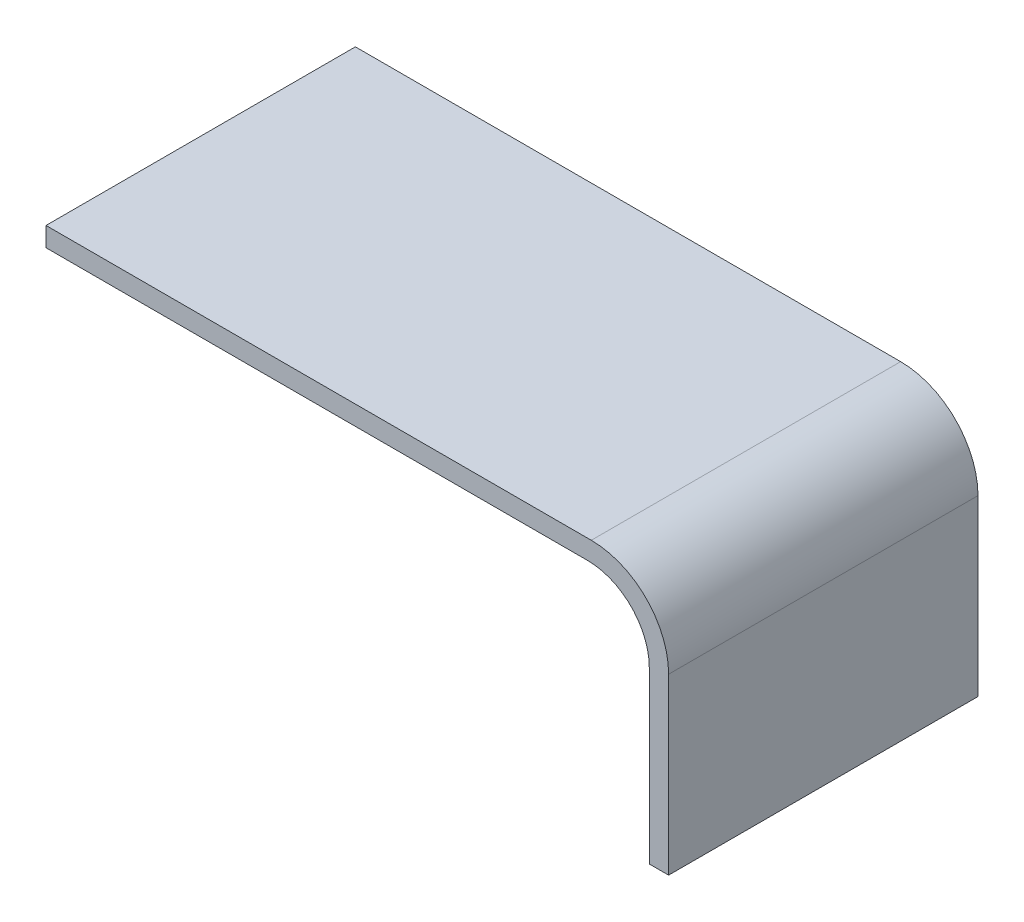
from build123d import *

# Parameters (mm, degrees)
BOSS_EXTRUDE1_DEPTH = 101.6


with BuildPart() as part:
    # Sketch2 → Boss-Extrude1 (new body)
    with BuildSketch(Plane.XY):
        with BuildLine():
            Line((204.47, 0), (383.54, 0))
            ThreePointArc((383.54, 0), (401.500512242, -7.439487758), (408.94, -25.4))
            Line((408.94, -25.4), (408.94, -82.55))
            Line((408.94, -82.55), (402.59, -82.55))
            Line((402.59, -82.55), (402.59, -26.67))
            ThreePointArc((402.59, -26.67), (396.638409794, -12.301590206), (382.27, -6.35))
            Line((382.27, -6.35), (204.47, -6.35))
            Line((204.47, -6.35), (204.47, 0))
        make_face()
    extrude(amount=BOSS_EXTRUDE1_DEPTH)


solid = part.part
